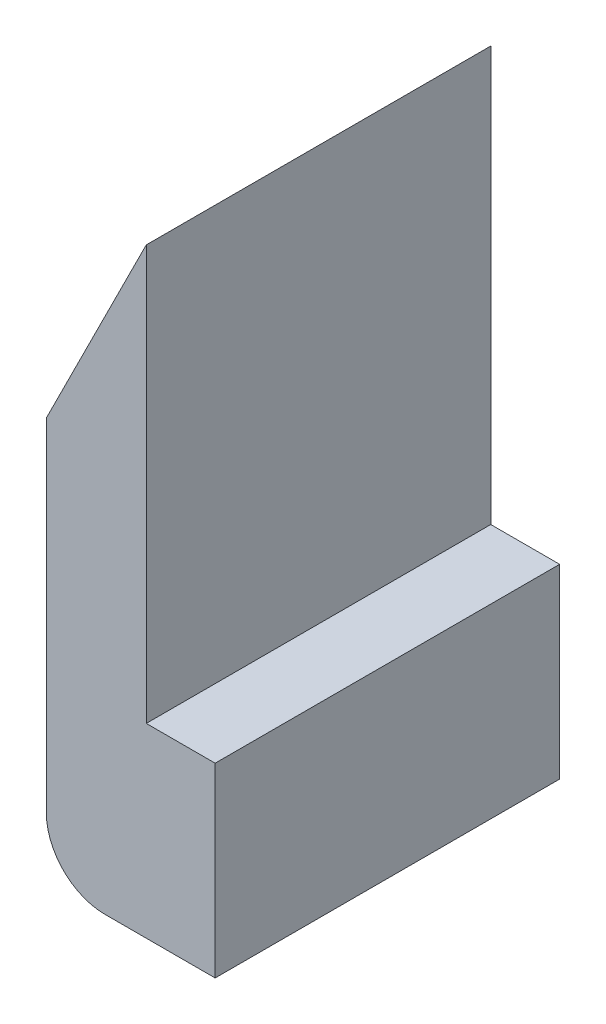
from build123d import *

# Parameters (mm, degrees)
BOSS_EXTRUDE1_DEPTH = 10


with BuildPart() as part:
    # Sketch1 → Boss-Extrude1 (new body)
    with BuildSketch(Plane.XY):
        with BuildLine():
            Line((-0.3, 11.729179607), (-3.2, 5.929179607))
            Line((-3.2, 5.929179607), (-3.2, -4))
            ThreePointArc((-3.2, -4), (-2.702081528, -5.202081528), (-1.5, -5.7))
            Line((-1.5, -5.7), (0, -5.7))
            Line((0, -5.7), (1.7, -5.7))
            Line((1.7, -5.7), (1.7, -0.3))
            Line((1.7, -0.3), (-0.3, -0.3))
            Line((-0.3, -0.3), (-0.3, 11.729179607))
        make_face()
    extrude(amount=BOSS_EXTRUDE1_DEPTH)


solid = part.part
